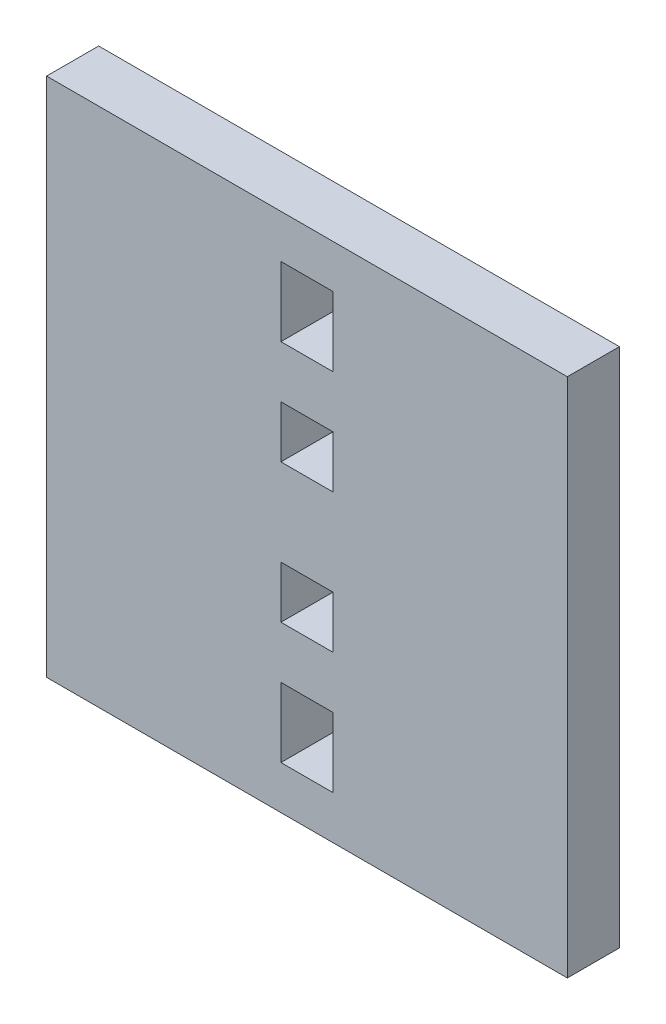
from build123d import *

# Parameters (mm, degrees)
SKETCH2_W           = 60
SKETCH2_H           = 60
SKETCH2_W_2         = 6
SKETCH2_H_2         = 8
SKETCH2_H_3         = 6
BOSS_EXTRUDE1_DEPTH = 6


with BuildPart() as part:
    # Sketch2 → Boss-Extrude1 (new body)
    with BuildSketch(Plane.XY):
        with Locations((0, 7.475728155)):
            Rectangle(SKETCH2_W, SKETCH2_H)
        with Locations((0, -13.524271845)):
            Rectangle(SKETCH2_W_2, SKETCH2_H_2, mode=Mode.SUBTRACT)
        with Locations((0, -0.524271845)):
            Rectangle(SKETCH2_W_2, SKETCH2_H_3, mode=Mode.SUBTRACT)
        with Locations((0, 28.475728155)):
            Rectangle(SKETCH2_W_2, SKETCH2_H_2, mode=Mode.SUBTRACT)
        with Locations((0, 15.475728155)):
            Rectangle(SKETCH2_W_2, SKETCH2_H_3, mode=Mode.SUBTRACT)
    extrude(amount=BOSS_EXTRUDE1_DEPTH)


solid = part.part
